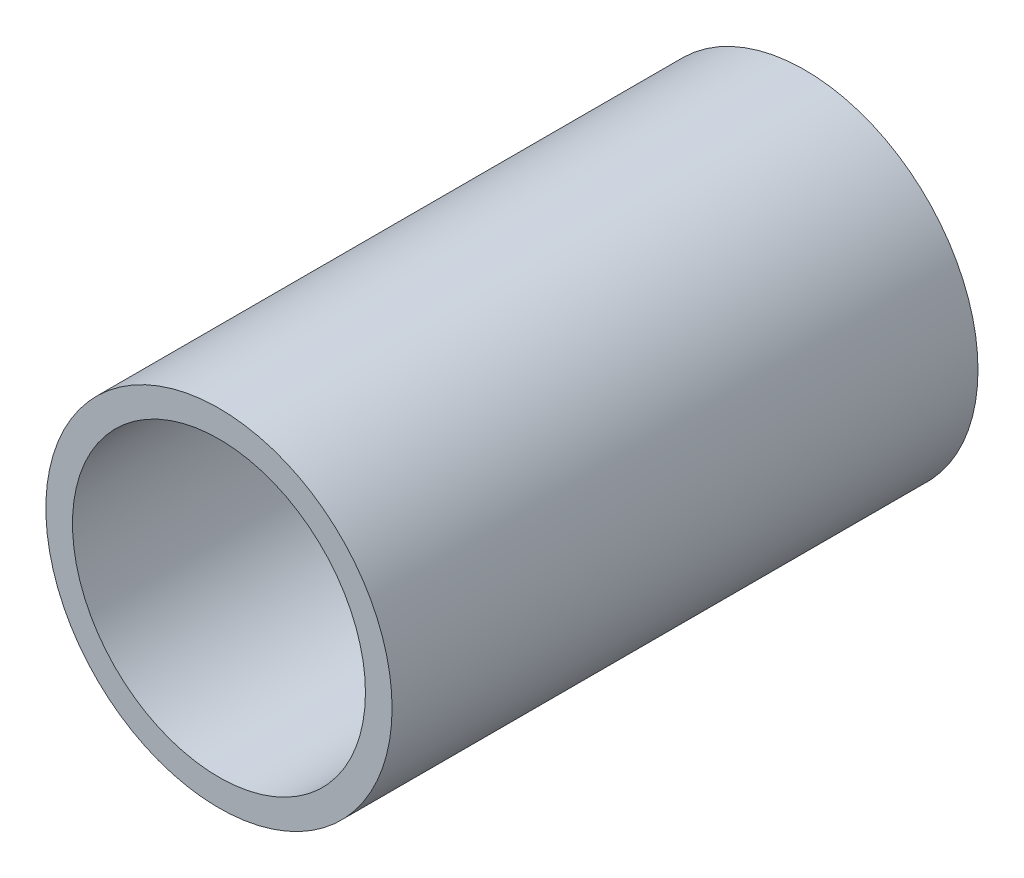
from build123d import *

# Parameters (mm, degrees)
SKETCH1_R           = 3.25
SKETCH1_R_2         = 2.75
BOSS_EXTRUDE1_DEPTH = 11


with BuildPart() as part:
    # Sketch1 → Boss-Extrude1 (new body)
    with BuildSketch(Plane.XY):
        Circle(SKETCH1_R)
        Circle(SKETCH1_R_2, mode=Mode.SUBTRACT)
    extrude(amount=BOSS_EXTRUDE1_DEPTH)


solid = part.part
